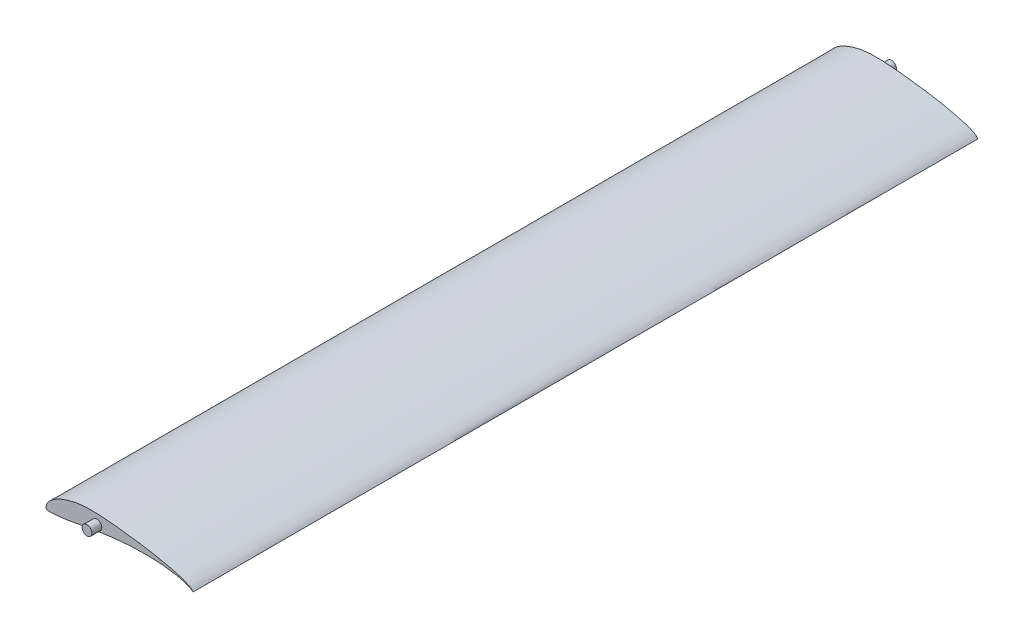
from build123d import *

# Parameters (mm, degrees)
BOSS_EXTRUDE1_DEPTH = 200
SKETCH2_R           = 2.5
BOSS_EXTRUDE2_DEPTH = 205


with BuildPart() as part:
    # Sketch1 → Boss-Extrude1 (new body, symmetric)
    with BuildSketch(Plane.XY):
        with BuildLine():
            add(Edge.make_bspline(
                [(75, 0), (75.000449645, 0.001909098), (74.753965085, 0.185688889), (74.54552451, 0.3903461), (74.082692959, 0.817822444), (73.536642881, 1.272594015), (72.789636965, 1.731122021), (71.860686137, 2.175558081), (70.739198847, 2.639433277), (69.426882591, 3.116293367), (67.929859324, 3.602770771), (66.255900032, 4.094643506), (64.414378573, 4.589602435), (62.41546241, 5.08310521), (60.270611595, 5.571580425), (57.992609921, 6.051977278), (55.595368081, 6.521825405), (53.092895834, 6.97534838), (50.500952478, 7.411894054), (47.834474522, 7.82584741), (45.110707344, 8.218009044), (42.347106837, 8.585272691), (39.563690282, 8.926459281), (36.782710749, 9.243970154), (34.027188758, 9.529809923), (31.31957209, 9.778638799), (28.678899703, 9.976497249), (26.12025285, 10.112854), (23.657861044, 10.172206552), (21.304343086, 10.166789388), (19.064073949, 10.052325656), (16.936182636, 9.819539667), (14.912014742, 9.490037806), (12.991081454, 9.062929585), (11.175364265, 8.561935217), (9.472548029, 7.995936506), (7.889878397, 7.378180566), (6.437190081, 6.711976641), (5.119145708, 6.010859135), (3.942917305, 5.282803802), (2.915882948, 4.537679368), (2.038471725, 3.791286995), (1.323401105, 3.035471575), (0.774074333, 2.276779444), (0.368239293, 1.538628769), (0.108063551, 0.83774659), (-0.01601796, 0.190792592), (0.007701736, -0.356421442), (0.148409214, -0.858345841), (0.671997953, -1.107661007), (1.376073178, -1.142856254), (2.33925026, -1.177064296), (3.550546067, -1.12524848), (4.996256187, -1.029758161), (6.660296564, -0.876579013), (8.525638798, -0.669188084), (10.583188875, -0.403118228), (12.831957644, -0.031030157), (15.282889623, 0.43568929), (17.948218631, 0.943629695), (20.814913182, 1.479923868), (23.864960902, 2.022277188), (27.075956485, 2.550304075), (30.422984135, 3.046343991), (33.877194516, 3.49216807), (37.407521786, 3.874771057), (40.980612744, 4.176933554), (44.56060887, 4.390768998), (48.11010624, 4.507781738), (51.590597249, 4.521517348), (54.963251278, 4.43097451), (58.189449809, 4.23825896), (61.230398318, 3.945856274), (64.049895149, 3.564962573), (66.611233449, 3.106614426), (68.884386088, 2.586143286), (70.8274655, 2.029384437), (72.417627959, 1.435329847), (73.552126735, 0.891804257), (74.388527361, 0.389315433), (74.709836026, 0.194861362), (74.999541214, -0.00194791), (75, 0)],
                knots=[0, 0, 0, 0, 0.000979678, 0.003648862, 0.007483499, 0.012095277, 0.017525591, 0.02405178, 0.031783051, 0.040677828, 0.050710301, 0.061833229, 0.07398925, 0.087118173, 0.101145049, 0.115990637, 0.131570422, 0.147788379, 0.164550917, 0.181757895, 0.199311955, 0.217095072, 0.234990228, 0.252856883, 0.270540594, 0.287886779, 0.304773438, 0.321101419, 0.336806063, 0.351800033, 0.366031063, 0.379615675, 0.392652963, 0.405170359, 0.417171919, 0.428603517, 0.439418959, 0.449596586, 0.459102079, 0.467907878, 0.475988301, 0.483308969, 0.489874508, 0.49580325, 0.501149412, 0.505903073, 0.510046769, 0.513579311, 0.516446927, 0.519350053, 0.523823355, 0.529973794, 0.537715654, 0.546967844, 0.557637367, 0.569620481, 0.582804124, 0.597246961, 0.613135037, 0.6304436, 0.649056124, 0.668822257, 0.689594964, 0.711189651, 0.733426689, 0.756094118, 0.778988554, 0.801889683, 0.824566598, 0.846792285, 0.868338291, 0.888978163, 0.908492011, 0.926658768, 0.943286193, 0.95816921, 0.971135822, 0.981955623, 0.990251791, 0.995852565, 0.999000406, 1, 1, 1, 1], degree=3))
        make_face()
    extrude(amount=BOSS_EXTRUDE1_DEPTH, both=True)

    # Sketch2 → Boss-Extrude2 (add)
    with BuildSketch(Plane.XY):
        with Locations((25.922705737, 5.14991333)):
            Circle(SKETCH2_R)
    boss_extrude2 = extrude(amount=BOSS_EXTRUDE2_DEPTH)

    # Mirror1: Boss-Extrude2 across plane
    add(boss_extrude2.mirror(Plane.XY))


solid = part.part
